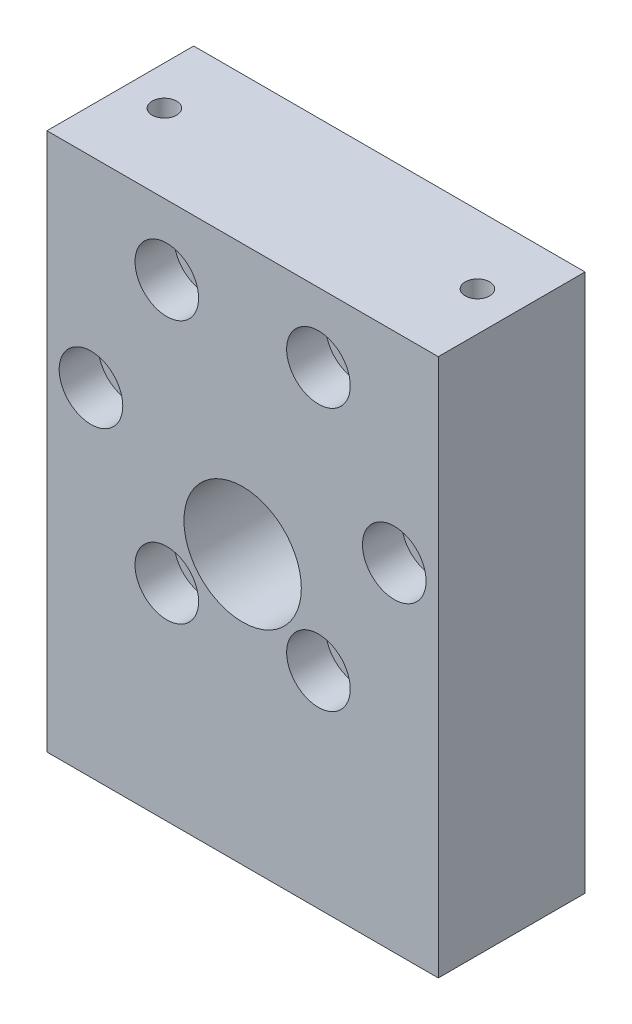
from build123d import *

# Parameters (mm, degrees)
SKETCH1_W             = 40
SKETCH1_H             = 55
SKETCH1_R             = 6
SKETCH1_R_2           = 1.5
BOSS_EXTRUDE1_DEPTH   = 15
SKETCH2_R             = 18.5
CUT_EXTRUDE1_DEPTH    = 6
M3_TAPPED_HOLE1_D     = 2.5
M3_TAPPED_HOLE1_DEPTH = 10
M3_TAPPED_HOLE1_TIP   = 0.751075774
M3_TAPPED_HOLE2_D     = 2.5
M3_TAPPED_HOLE2_DEPTH = 8
M3_TAPPED_HOLE2_TIP   = 0.751075774
SKETCH7_R             = 3.25
CUT_EXTRUDE2_DEPTH    = 4
CUT_EXTRUDE3_DEPTH    = 12
FILLET1_R             = 2
SKETCH10_W            = 3
SKETCH10_H            = 48
BOSS_EXTRUDE2_DEPTH   = 15


with BuildPart() as part:
    # Sketch1 → Boss-Extrude1 (new body)
    with BuildSketch(Plane.XY):
        Rectangle(SKETCH1_W, SKETCH1_H)
        Circle(SKETCH1_R, mode=Mode.SUBTRACT)
        with Locations((15.5, 7)):
            Circle(SKETCH1_R_2, mode=Mode.SUBTRACT)
        with Locations((7.75, -6.423393759)):
            Circle(SKETCH1_R_2, mode=Mode.SUBTRACT)
        with Locations((-7.75, -6.423393759)):
            Circle(SKETCH1_R_2, mode=Mode.SUBTRACT)
        with Locations((-15.5, 7)):
            Circle(SKETCH1_R_2, mode=Mode.SUBTRACT)
        with Locations((-7.75, 20.423393759)):
            Circle(SKETCH1_R_2, mode=Mode.SUBTRACT)
        with Locations((7.75, 20.423393759)):
            Circle(SKETCH1_R_2, mode=Mode.SUBTRACT)
    extrude(amount=BOSS_EXTRUDE1_DEPTH)

    # Sketch2 → Cut-Extrude1 (cut)
    with BuildSketch(Plane(origin=(0, 0, 0), x_dir=(-1, 0, 0), z_dir=(0, 0, -1))):
        with Locations((0, 7)):
            Circle(SKETCH2_R)
    extrude(amount=-CUT_EXTRUDE1_DEPTH, mode=Mode.SUBTRACT)

    # M3 Tapped Hole1
    with Locations(Plane(origin=(0, -27.5, 0), x_dir=(-1, 0, 0), z_dir=(0, -1, 0))):
        with Locations((-10, -7), (10, -7)):
            Hole(M3_TAPPED_HOLE1_D / 2, depth=M3_TAPPED_HOLE1_DEPTH)
            with Locations((0, 0, -(M3_TAPPED_HOLE1_DEPTH + M3_TAPPED_HOLE1_TIP / 2))):  # 118° drill point
                Cone(0, M3_TAPPED_HOLE1_D / 2, M3_TAPPED_HOLE1_TIP, mode=Mode.SUBTRACT)

    # M3 Tapped Hole2
    with Locations(Plane(origin=(0, 27.5, 0), x_dir=(1, 0, 0), z_dir=(0, 1, 0))):
        with Locations((-16, -7), (16, -7)):
            Hole(M3_TAPPED_HOLE2_D / 2, depth=M3_TAPPED_HOLE2_DEPTH)
            with Locations((0, 0, -(M3_TAPPED_HOLE2_DEPTH + M3_TAPPED_HOLE2_TIP / 2))):  # 118° drill point
                Cone(0, M3_TAPPED_HOLE2_D / 2, M3_TAPPED_HOLE2_TIP, mode=Mode.SUBTRACT)

    # Sketch7 → Cut-Extrude2 (cut)
    with BuildSketch(Plane.XY.offset(15)):
        with Locations((-7.75, 20.423393759)):
            Circle(SKETCH7_R)
        with Locations((7.75, 20.423393759)):
            Circle(SKETCH7_R)
        with Locations((15.5, 7)):
            Circle(SKETCH7_R)
        with Locations((7.75, -6.423393759)):
            Circle(SKETCH7_R)
        with Locations((-7.75, -6.423393759)):
            Circle(SKETCH7_R)
        with Locations((-15.5, 7)):
            Circle(SKETCH7_R)
    extrude(amount=-CUT_EXTRUDE2_DEPTH, mode=Mode.SUBTRACT)

    # Sketch9 → Cut-Extrude3 (cut)
    with BuildSketch(Plane(origin=(0, 0, 0), x_dir=(-1, 0, 0), z_dir=(0, 0, -1))):
        with BuildLine():
            Line((-18, -25.5), (-13.25, -25.5))
            Line((-13.25, -25.5), (-13.25, -15.5))
            Line((-13.25, -15.5), (-6.75, -15.5))
            Line((-6.75, -15.5), (-6.75, -25.5))
            Line((-6.75, -25.5), (6.75, -25.5))
            Line((6.75, -25.5), (6.75, -15.5))
            Line((6.75, -15.5), (13.25, -15.5))
            Line((13.25, -15.5), (13.25, -25.5))
            Line((13.25, -25.5), (18, -25.5))
            Line((18, -25.5), (18, -2.810708435))
            ThreePointArc((18, -2.810708435), (0, -13.5), (-18, -2.810708435))
            Line((-18, -2.810708435), (-18, -25.5))
        make_face()
    extrude(amount=-CUT_EXTRUDE3_DEPTH, mode=Mode.SUBTRACT)

    # Fillet1
    fillet1_edges = [part.edges().sort_by_distance(p)[0] for p in [
        (18, -25.5, 6),
        (18, -2.810708435, 6),
        (-18, -2.810708435, 6),
        (-18, -25.5, 6),
        (-13.25, -25.5, 6),
        (-13.25, -15.5, 6),
        (-6.75, -15.5, 6),
        (-6.75, -25.5, 6),
        (6.75, -25.5, 6),
        (6.75, -15.5, 6),
        (13.25, -15.5, 6),
        (13.25, -25.5, 6),
    ]]
    fillet(fillet1_edges, radius=FILLET1_R)

    # Sketch10 → Boss-Extrude2 (add)
    with BuildSketch(Plane.XY.offset(15)):
        with Locations((-21.5, 3.5)):
            Rectangle(SKETCH10_W, SKETCH10_H)
        with Locations((21.5, 3.5)):
            Rectangle(SKETCH10_W, SKETCH10_H)
    extrude(amount=BOSS_EXTRUDE2_DEPTH)


with BuildPart() as boss_extrude2_kept_piece:
    # of the separate pieces the step leaves, the one the design keeps (boss_extrude2_pieces_kept)
    add(part.part.solids().sort_by_distance((18, -8.81929202, 0))[0])


solid = boss_extrude2_kept_piece.part
